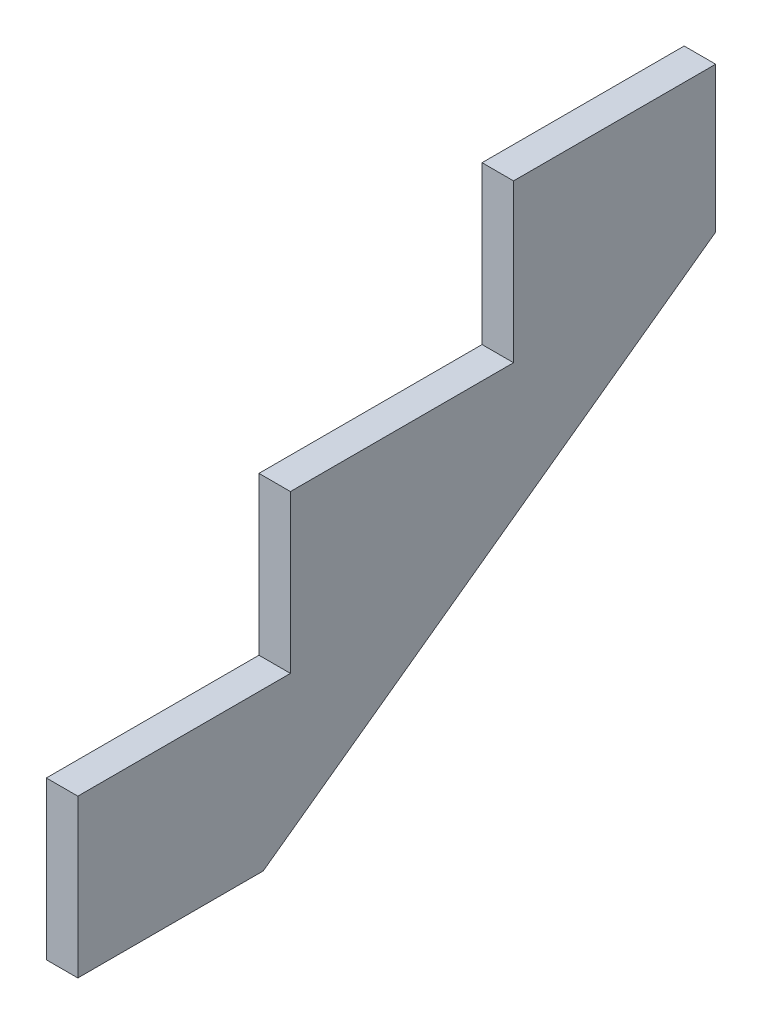
from build123d import *

# Parameters (mm, degrees)
BOSS_EXTRUDE2_DEPTH = 38.1


with BuildPart() as part:
    # Sketch1 → Boss-Extrude2 (new body)
    with BuildSketch(Plane(origin=(0, 0, 0), x_dir=(0, 0, -1), z_dir=(1, 0, 0))):
        Polygon((0, 0), (0, 190.5), (257.175, 190.5), (257.175, 381), (527.05, 381), (527.05, 571.5), (771.525, 571.5), (771.525, 395.634695119), (224.230338419, 0), align=None)
    extrude(amount=BOSS_EXTRUDE2_DEPTH)


solid = part.part
